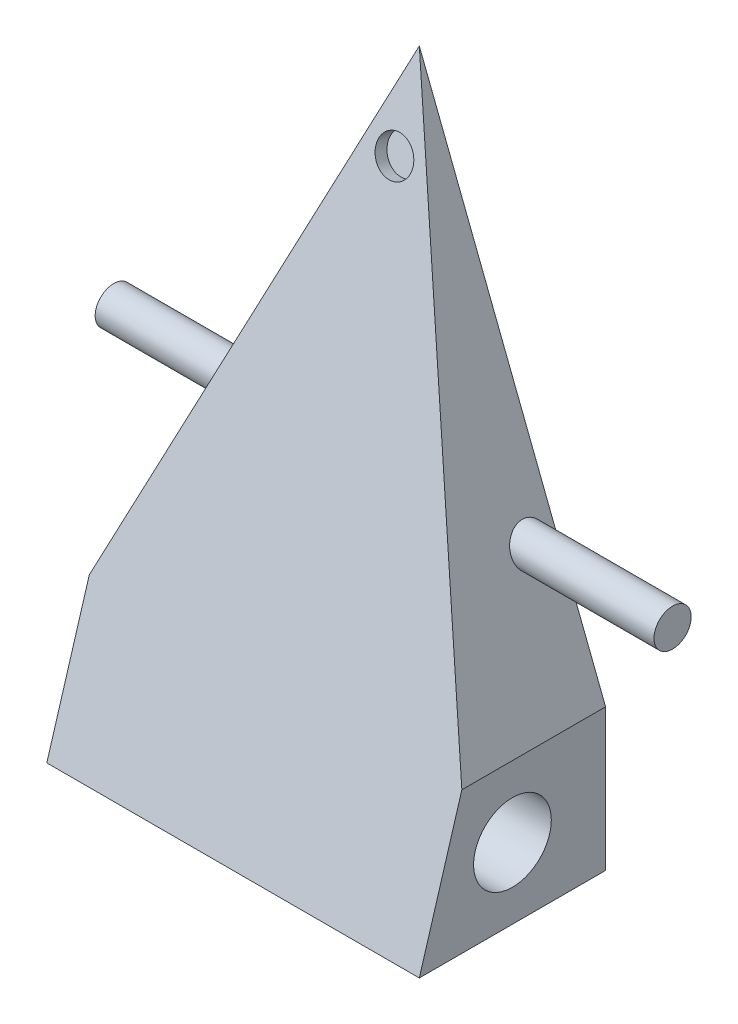
from build123d import *

# Parameters (mm, degrees)
SKETCH2_W           = 30
SKETCH2_H           = 100
EXTRUDE_THIN1_DEPTH = 60
CUT_EXTRUDE1_DEPTH  = 60
CUT_EXTRUDE2_DEPTH  = 60
CUT_EXTRUDE3_DEPTH  = 60
SKETCH6_R           = 6.257784416
CUT_EXTRUDE4_DEPTH  = 61
SKETCH7_R           = 3
CUT_EXTRUDE5_DEPTH  = 2
BOSS_EXTRUDE1_START = -75
SKETCH10_R          = 3
BOSS_EXTRUDE1_DEPTH = 90


with BuildPart() as part:
    # Sketch2 → Extrude-Thin1 (new body)
    with BuildSketch(Plane(origin=(0, 0, 0), x_dir=(0, 0, -1), z_dir=(1, 0, 0))):
        with Locations((15, 13.4875)):
            Rectangle(SKETCH2_W, SKETCH2_H)
    extrude(amount=EXTRUDE_THIN1_DEPTH)

    # Sketch3 → Cut-Extrude1 (cut)
    with BuildSketch(Plane(origin=(60, 0, 0), x_dir=(0, 0, -1), z_dir=(1, 0, 0))):
        Polygon((0, 63.4875), (0, -36.5125), (30, 63.4875), align=None)
    extrude(amount=-CUT_EXTRUDE1_DEPTH, mode=Mode.SUBTRACT)

    # Sketch4 → Cut-Extrude2 (cut)
    with BuildSketch(Plane(origin=(0, 0, -30), x_dir=(-1, 0, 0), z_dir=(0, 0, -1))):
        Polygon((-30, 63.4875), (-60, -13.684128909), (-60, 63.4875), align=None)
    extrude(amount=-CUT_EXTRUDE2_DEPTH, mode=Mode.SUBTRACT)

    # Sketch5 → Cut-Extrude3 (cut)
    with BuildSketch(Plane(origin=(0, 0, -30), x_dir=(-1, 0, 0), z_dir=(0, 0, -1))):
        Polygon((-30, 63.4875), (0, 63.4875), (0, -13.684128909), align=None)
    extrude(amount=-CUT_EXTRUDE3_DEPTH, mode=Mode.SUBTRACT)

    # Sketch6 → Cut-Extrude4 (cut, through all)
    with BuildSketch(Plane(origin=(60, 0, 0), x_dir=(0, 0, -1), z_dir=(1, 0, 0))):
        with Locations((15, -25.098314454)):
            Circle(SKETCH6_R)
    extrude(amount=-CUT_EXTRUDE4_DEPTH, mode=Mode.SUBTRACT)

    # Sketch7 → Cut-Extrude5 (cut)
    with BuildSketch(Plane(origin=(0, -3.014793578, -10.049311927), x_dir=(1, 0, 0), z_dir=(0, 0.287347886, 0.957826285))):
        with Locations((30, 55.48605385)):
            Circle(SKETCH7_R)
    extrude(amount=-CUT_EXTRUDE5_DEPTH, mode=Mode.SUBTRACT)

    # Sketch10 → Boss-Extrude1 (add)
    with BuildSketch(Plane(origin=(60, 0, 0), x_dir=(0, 0, -1), z_dir=(1, 0, 0)).offset(BOSS_EXTRUDE1_START)):
        with Locations((25.790784961, 6.968067419)):
            Circle(SKETCH10_R)
    extrude(amount=BOSS_EXTRUDE1_DEPTH)


solid = part.part
